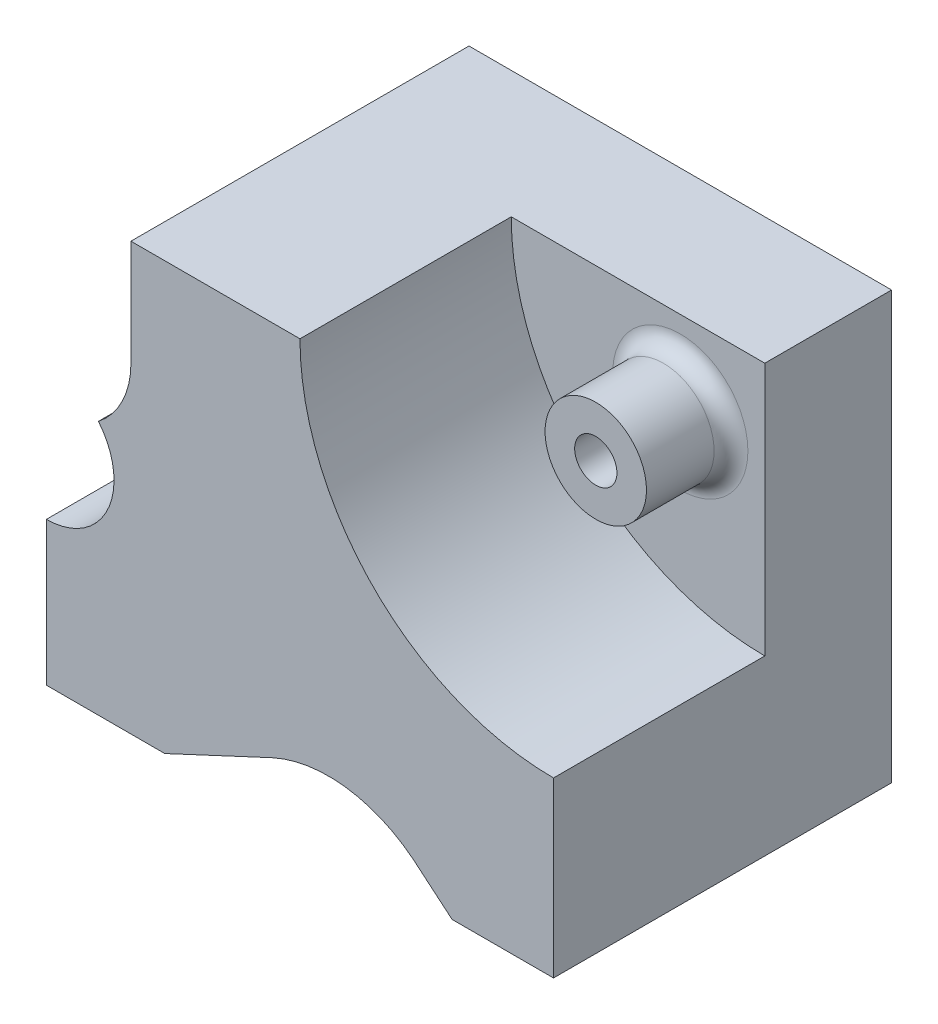
from build123d import *

# Parameters (mm, degrees)
BOSS_EXTRUDE1_DEPTH = 40
CUT_EXTRUDE1_DEPTH  = 25
CUT_EXTRUDE2_DEPTH  = 15
SKETCH3_R           = 2.5
CUT_EXTRUDE3_DEPTH  = 83.311906794
BOSS_EXTRUDE2_START = 10
SKETCH3_6_R         = 6
SKETCH3_6_R_2       = 2.5
BOSS_EXTRUDE2_DEPTH = 10
FILLET2_R           = 2


with BuildPart() as part:
    # Sketch1 → Boss-Extrude1 (new body)
    with BuildSketch(Plane.XY):
        with BuildLine():
            Line((0, 0), (-50, 0))
            Line((-50, 0), (-50, -12.5))
            Line((-50, -12.5), (-60, -12.5))
            Line((-60, -12.5), (-60, -50.5))
            Line((-60, -50.5), (-46, -50.5))
            Line((-46, -50.5), (-33.311690981, -44.583344336))
            ThreePointArc((-33.311690981, -44.583344336), (-24.66100943, -43.235991833), (-16.596266659, -46.643274342))
            Line((-16.596266659, -46.643274342), (-12, -50.5))
            Line((-12, -50.5), (0, -50.5))
            Line((0, -50.5), (0, 0))
        make_face()
    extrude(amount=-BOSS_EXTRUDE1_DEPTH)

    # Sketch2 → Cut-Extrude1 (cut)
    with BuildSketch(Plane.XY):
        with BuildLine():
            ThreePointArc((-60, -22.5), (-52.928932188, -19.571067812), (-50, -12.5))
            Line((-50, -12.5), (-60, -12.5))
            Line((-60, -12.5), (-60, -22.5))
        make_face()
        with BuildLine():
            Line((0, 0), (-30, 0))
            ThreePointArc((-30, 0), (-21.213203436, -21.213203436), (0, -30))
            Line((0, -30), (0, 0))
        make_face()
    extrude(amount=-CUT_EXTRUDE1_DEPTH, mode=Mode.SUBTRACT)

    # Sketch2_7 → Cut-Extrude2 (cut)
    with BuildSketch(Plane.XY):
        with BuildLine():
            ThreePointArc((-60, -33.5), (-52.756966211, -28.896831102), (-53.849159388, -20.384615385))
            ThreePointArc((-53.849159388, -20.384615385), (-56.747781822, -21.956377579), (-60, -22.5))
            Line((-60, -22.5), (-60, -33.5))
        make_face()
    extrude(amount=-CUT_EXTRUDE2_DEPTH, mode=Mode.SUBTRACT)

    # Sketch3 → Cut-Extrude3 (cut, through all)
    with BuildSketch(Plane.XY.offset(-25)):
        with Locations((-10, -10)):
            Circle(SKETCH3_R)
    extrude(amount=-CUT_EXTRUDE3_DEPTH, mode=Mode.SUBTRACT)

    # Sketch3_6 → Boss-Extrude2 (add)
    with BuildSketch(Plane.XY.offset(-25).offset(BOSS_EXTRUDE2_START)):
        with Locations((-10, -10)):
            Circle(SKETCH3_6_R)
        with Locations((-10, -10)):
            Circle(SKETCH3_6_R_2, mode=Mode.SUBTRACT)
    extrude(amount=-BOSS_EXTRUDE2_DEPTH)

    # Fillet2
    fillet2_edges = [part.edges().sort_by_distance(p)[0] for p in [
        (-16, -10, -25),
    ]]
    fillet(fillet2_edges, radius=FILLET2_R)


solid = part.part
